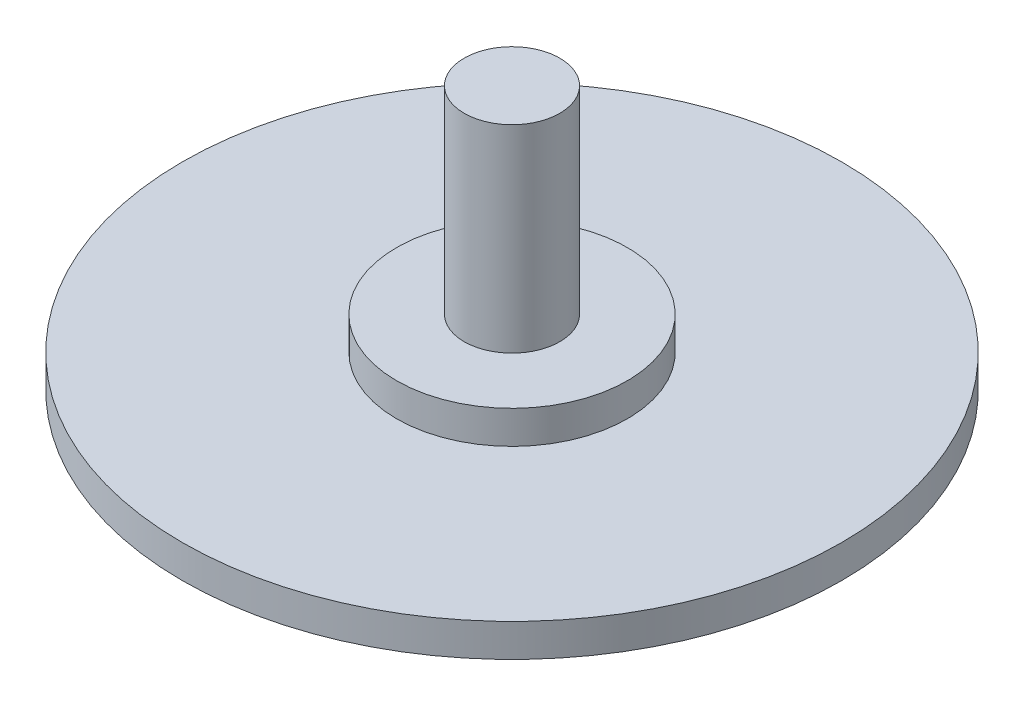
from build123d import *

# Parameters (mm, degrees)
ESQUISSE1_R        = 10
BOSS_EXTRU_1_DEPTH = 1
ESQUISSE2_R        = 1.45
BOSS_EXTRU_2_DEPTH = 7
ESQUISSE3_R        = 3.5
BOSS_EXTRU_3_DEPTH = 1


with BuildPart() as part:
    # Esquisse1 → Boss.-Extru.1 (new body)
    with BuildSketch(Plane(origin=(0, 0, 0), x_dir=(1, 0, 0), z_dir=(0, 1, 0))):
        Circle(ESQUISSE1_R)
    extrude(amount=BOSS_EXTRU_1_DEPTH)

    # Esquisse2 → Boss.-Extru.2 (add)
    with BuildSketch(Plane(origin=(0, 1, 0), x_dir=(1, 0, 0), z_dir=(0, 1, 0))):
        Circle(ESQUISSE2_R)
    extrude(amount=BOSS_EXTRU_2_DEPTH)

    # Esquisse3 → Boss.-Extru.3 (add)
    with BuildSketch(Plane(origin=(0, 1, 0), x_dir=(1, 0, 0), z_dir=(0, 1, 0))):
        Circle(ESQUISSE3_R)
    extrude(amount=BOSS_EXTRU_3_DEPTH)


solid = part.part
